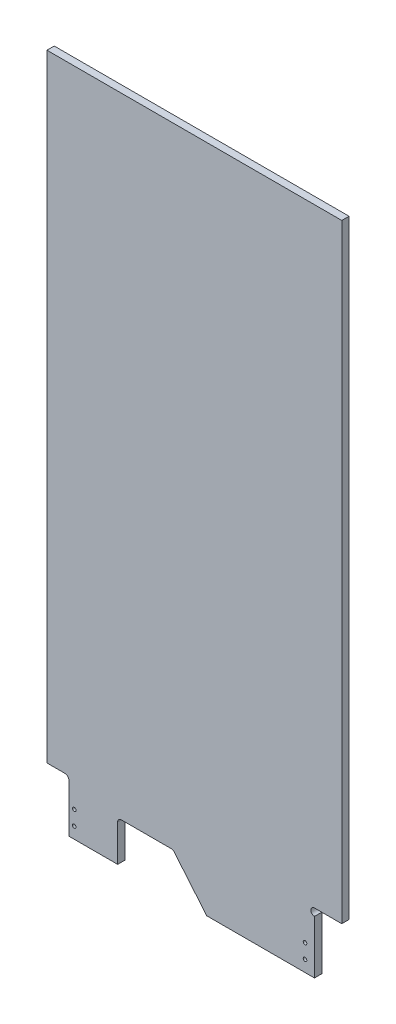
from build123d import *

# Parameters (mm, degrees)
EXTRUDE1_DEPTH     = 12.7
SKETCH3_R          = 3.1115
CUT_EXTRUDE1_DEPTH = 12.7


with BuildPart() as part:
    # Sketch2 → Extrude1 (new body)
    with BuildSketch(Plane.XY):
        with BuildLine():
            Line((10375.902142089, 13017.500110193), (10461.202782059, 13017.500110193))
            Line((10461.202782059, 13017.500110193), (10461.202782059, 13081.594724716))
            ThreePointArc((10461.202782059, 13081.594724716), (10463.062653998, 13086.084852777), (10467.552782059, 13087.944724716))
            Line((10467.552782059, 13087.944724716), (10554.77765388, 13087.944724716))
            ThreePointArc((10554.77765388, 13087.944724716), (10557.466824452, 13087.347190416), (10559.649893716, 13085.667043341))
            Line((10559.649893716, 13085.667043341), (10616.625223517, 13017.500110193))
            Line((10616.625223517, 13017.500110193), (10804.525747814, 13017.500110193))
            Line((10804.525747814, 13017.500110193), (10804.525747814, 13110.590509206))
            ThreePointArc((10804.525747814, 13110.590509206), (10798.175747814, 13116.940509206), (10804.525747814, 13123.290509206))
            Line((10804.525747814, 13123.290509206), (10852.150747814, 13123.290509206))
            Line((10852.150747814, 13123.290509206), (10852.147924282, 14185.900110193))
            Line((10852.147924282, 14185.900110193), (10337.800747814, 14185.900110193))
            Line((10337.800747814, 14185.900110193), (10337.802142089, 13109.003009206))
            Line((10337.802142089, 13109.003009206), (10369.552142089, 13109.003009206))
            ThreePointArc((10369.552142089, 13109.003009206), (10374.042270149, 13107.143137266), (10375.902142089, 13102.653009206))
            Line((10375.902142089, 13102.653009206), (10375.902142089, 13017.500110193))
        make_face()
    extrude(amount=-EXTRUDE1_DEPTH)

    # Sketch3 → Cut-Extrude1 (cut)
    with BuildSketch(Plane.XY):
        with Locations((10385.425050678, 13062.712110193)):
            Circle(SKETCH3_R)
        with Locations((10385.425050678, 13037.312110193)):
            Circle(SKETCH3_R)
        with Locations((10788.015050678, 13062.712110193)):
            Circle(SKETCH3_R)
        with Locations((10788.015050678, 13037.312110193)):
            Circle(SKETCH3_R)
    extrude(amount=-CUT_EXTRUDE1_DEPTH, mode=Mode.SUBTRACT)


solid = part.part
